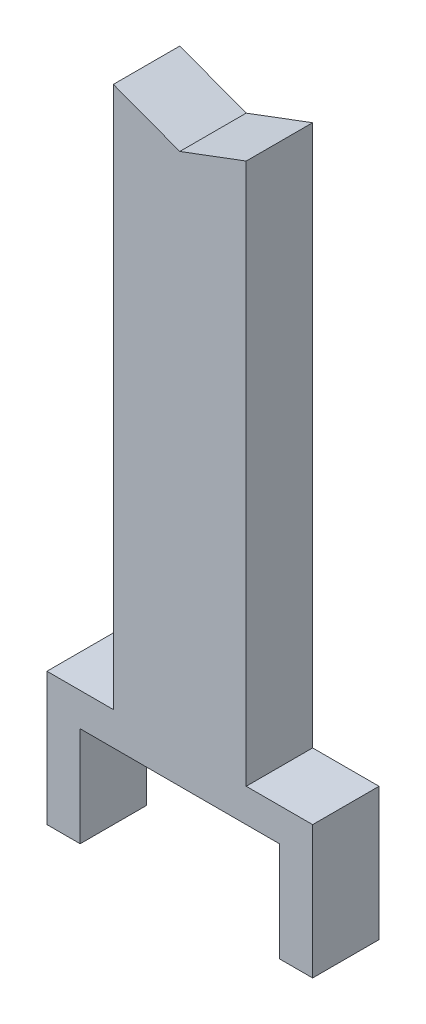
from build123d import *

# Parameters (mm, degrees)
BOSS_EXTRUDE1_DEPTH = 25.4


with BuildPart() as part:
    # Sketch1 → Boss-Extrude1 (new body, symmetric)
    with BuildSketch(Plane.XY):
        Polygon((0, 496.697), (-50.8, 515.747), (-50.8, 101.6), (-101.6, 101.6), (-101.6, 0), (-76.2, 0), (-76.2, 76.2), (0, 76.2), (76.2, 76.2), (76.2, 0), (101.6, 0), (101.6, 101.6), (50.8, 101.6), (50.8, 515.747), align=None)
    extrude(amount=BOSS_EXTRUDE1_DEPTH, both=True)


solid = part.part
